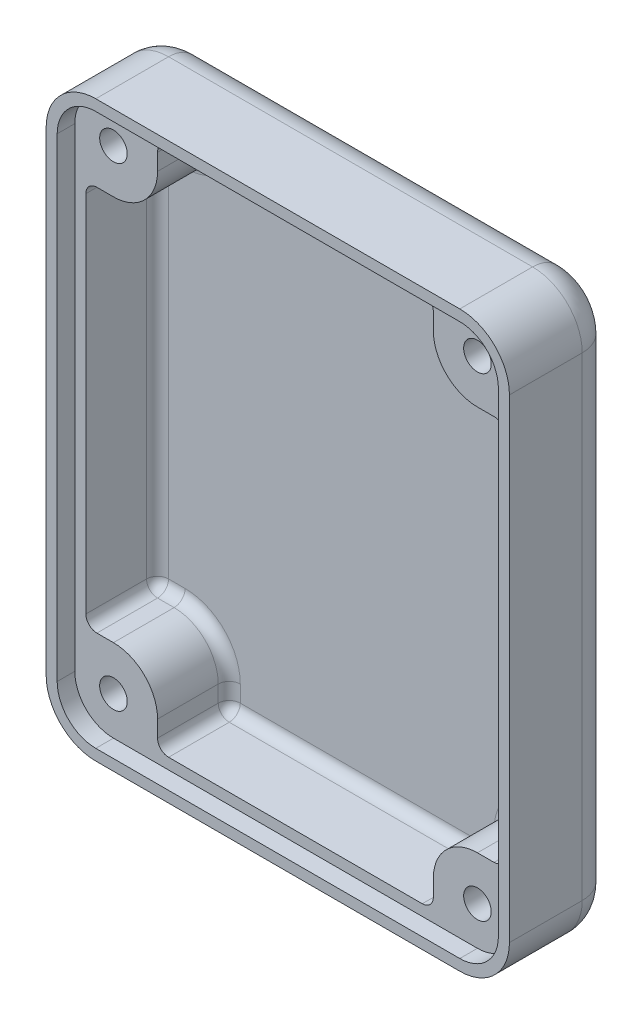
from build123d import *

# Parameters (mm, degrees)
BOSS_EXTRUDE1_DEPTH = 9.6
CUT_EXTRUDE1_START  = 9.6
CUT_EXTRUDE1_DEPTH  = 1.6
CUT_EXTRUDE2_START  = 9.6
CUT_EXTRUDE2_DEPTH  = 8.1
CUT_EXTRUDE3_START  = 9.6
SKETCH5_R           = 1.25
CUT_EXTRUDE3_DEPTH  = 8.1
FILLET2_R           = 1
FILLET3_R           = 3


with BuildPart() as part:
    # Sketch2 → Boss-Extrude1 (new body)
    with BuildSketch(Plane.XY):
        with BuildLine():
            Line((21, 21.5), (21, -21.5))
            ThreePointArc((21, -21.5), (19.681980515, -24.681980515), (16.5, -26))
            Line((16.5, -26), (-16.5, -26))
            ThreePointArc((-16.5, -26), (-19.681980515, -24.681980515), (-21, -21.5))
            Line((-21, -21.5), (-21, 21.5))
            ThreePointArc((-21, 21.5), (-19.681980515, 24.681980515), (-16.5, 26))
            Line((-16.5, 26), (16.5, 26))
            ThreePointArc((16.5, 26), (19.681980515, 24.681980515), (21, 21.5))
        make_face()
    extrude(amount=BOSS_EXTRUDE1_DEPTH)

    # Sketch3 → Cut-Extrude1 (cut)
    with BuildSketch(Plane.XY.offset(CUT_EXTRUDE1_START)):
        with BuildLine():
            Line((-20, 21.5), (-20, -21.5))
            ThreePointArc((-20, -21.5), (-18.974873734, -23.974873734), (-16.5, -25))
            Line((-16.5, -25), (16.5, -25))
            ThreePointArc((16.5, -25), (18.974873734, -23.974873734), (20, -21.5))
            Line((20, -21.5), (20, 21.5))
            ThreePointArc((20, 21.5), (18.974873734, 23.974873734), (16.5, 25))
            Line((16.5, 25), (-16.5, 25))
            ThreePointArc((-16.5, 25), (-18.974873734, 23.974873734), (-20, 21.5))
        make_face()
    extrude(amount=-CUT_EXTRUDE1_DEPTH, mode=Mode.SUBTRACT)

    # Sketch4 → Cut-Extrude2 (cut)
    with BuildSketch(Plane.XY.offset(CUT_EXTRUDE2_START)):
        with BuildLine():
            Line((-12.5, -21.5), (-12.5, -24))
            Line((-12.5, -24), (12.5, -24))
            Line((12.5, -24), (12.5, -21.5))
            ThreePointArc((12.5, -21.5), (13.671572875, -18.671572875), (16.5, -17.5))
            Line((16.5, -17.5), (19, -17.5))
            Line((19, -17.5), (19, 17.5))
            Line((19, 17.5), (16.5, 17.5))
            ThreePointArc((16.5, 17.5), (13.671572875, 18.671572875), (12.5, 21.5))
            Line((12.5, 21.5), (12.5, 24))
            Line((12.5, 24), (-12.5, 24))
            Line((-12.5, 24), (-12.5, 21.5))
            ThreePointArc((-12.5, 21.5), (-13.671572875, 18.671572875), (-16.5, 17.5))
            Line((-16.5, 17.5), (-19, 17.5))
            Line((-19, 17.5), (-19, -17.5))
            Line((-19, -17.5), (-16.5, -17.5))
            ThreePointArc((-16.5, -17.5), (-13.671572875, -18.671572875), (-12.5, -21.5))
        make_face()
    extrude(amount=-CUT_EXTRUDE2_DEPTH, mode=Mode.SUBTRACT)

    # Sketch5 → Cut-Extrude3 (cut)
    with BuildSketch(Plane.XY.offset(CUT_EXTRUDE3_START)):
        with Locations((-16.5, 21.5)):
            Circle(SKETCH5_R)
        with Locations((16.5, 21.5)):
            Circle(SKETCH5_R)
        with Locations((-16.5, -21.5)):
            Circle(SKETCH5_R)
        with Locations((16.5, -21.5)):
            Circle(SKETCH5_R)
    extrude(amount=-CUT_EXTRUDE3_DEPTH, mode=Mode.SUBTRACT)

    # Fillet2
    fillet2_edges = [part.edges().sort_by_distance(p)[0] for p in [
        (13.671572875, -18.671572875, 1.5),
        (12.5, -22.75, 1.5),
        (0, -24, 1.5),
        (12.5, -24, 4.75),
        (-12.5, -22.75, 1.5),
        (-12.5, -24, 4.75),
        (-13.671572875, -18.671572875, 1.5),
        (-17.75, -17.5, 1.5),
        (-19, 0, 1.5),
        (-19, -17.5, 4.75),
        (-17.75, 17.5, 1.5),
        (-19, 17.5, 4.75),
        (-13.671572875, 18.671572875, 1.5),
        (-12.5, 22.75, 1.5),
        (0, 24, 1.5),
        (-12.5, 24, 4.75),
        (12.5, 22.75, 1.5),
        (12.5, 24, 4.75),
        (13.671572875, 18.671572875, 1.5),
        (17.75, 17.5, 1.5),
        (19, 0, 1.5),
        (19, 17.5, 4.75),
        (17.75, -17.5, 1.5),
        (19, -17.5, 4.75),
    ]]
    fillet(fillet2_edges, radius=FILLET2_R)

    # Fillet3
    fillet3_edges = [part.edges().sort_by_distance(p)[0] for p in [
        (-21, 0, 0),
        (-19.681980515, 24.681980515, 0),
        (0, 26, 0),
        (19.681980515, 24.681980515, 0),
        (21, 0, 0),
        (19.681980515, -24.681980515, 0),
        (0, -26, 0),
        (-19.681980515, -24.681980515, 0),
    ]]
    fillet(fillet3_edges, radius=FILLET3_R)


solid = part.part
